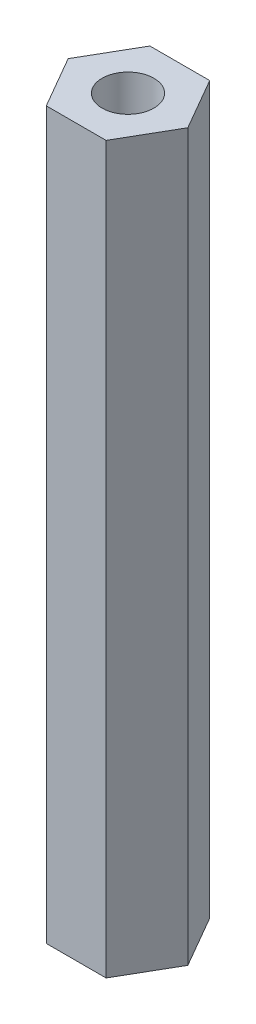
from build123d import *

# Parameters (mm, degrees)
SKETCH1_R           = 1.5
BOSS_EXTRUDE1_DEPTH = 42


with BuildPart() as part:
    # Sketch1 → Boss-Extrude1 (new body)
    with BuildSketch(Plane(origin=(0, 0, 0), x_dir=(1, 0, 0), z_dir=(0, 1, 0))):
        Polygon((1.732050808, 3), (-1.732050808, 3), (-3.464101615, 0), (-1.732050808, -3), (1.732050808, -3), (3.464101615, 0), align=None)
        Circle(SKETCH1_R, mode=Mode.SUBTRACT)
    extrude(amount=BOSS_EXTRUDE1_DEPTH)


solid = part.part
